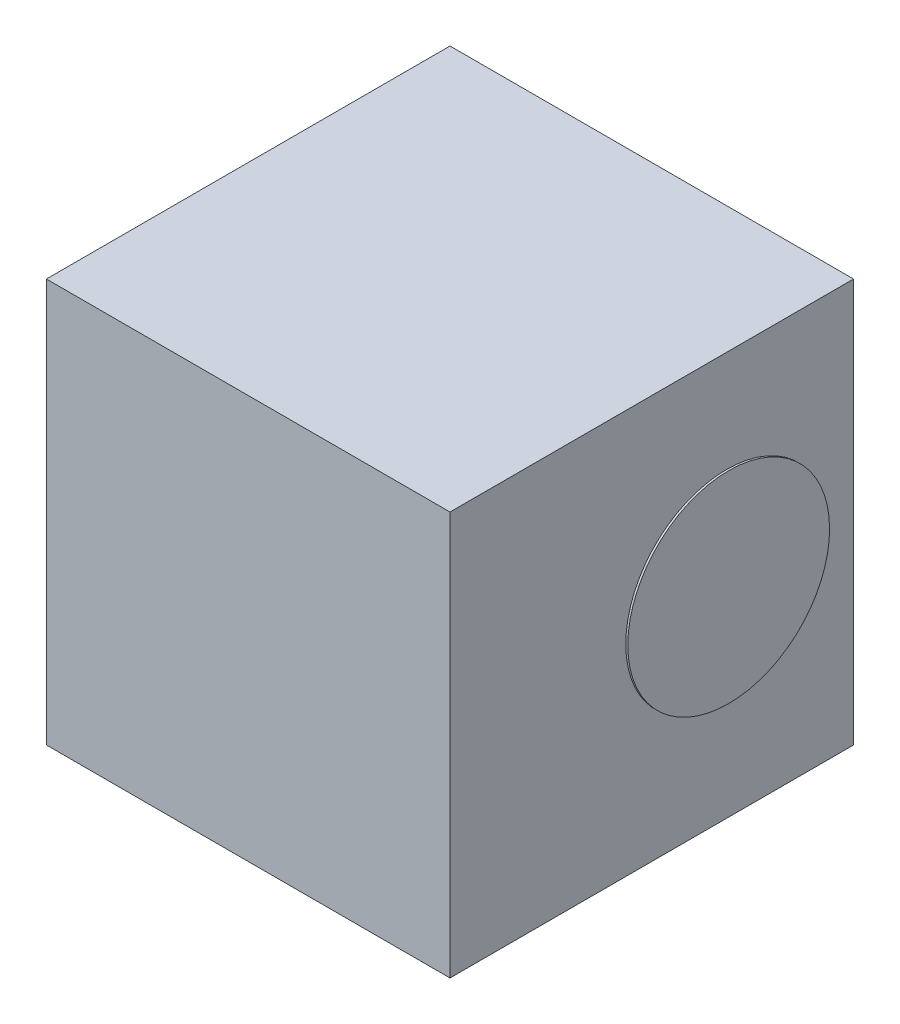
from build123d import *

# Parameters (mm, degrees)
SKETCH1_W           = 2
SKETCH1_H           = 2
BOSS_EXTRUDE1_DEPTH = 2
SKETCH2_R           = 0.5
BOSS_EXTRUDE2_DEPTH = 0.01


with BuildPart() as part:
    # Sketch1 → Boss-Extrude1 (new body)
    with BuildSketch(Plane(origin=(0, 0, 0), x_dir=(1, 0, 0), z_dir=(0, 1, 0))):
        Rectangle(SKETCH1_W, SKETCH1_H)
    extrude(amount=BOSS_EXTRUDE1_DEPTH)

    # Sketch2 → Boss-Extrude2 (add)
    with BuildSketch(Plane(origin=(1, 0, 0), x_dir=(0, 0, -1), z_dir=(1, 0, 0))):
        with Locations(Location((0.371123836, 0.997145201, 0), (0, 0, 180))):  # turned: the seam where the file's is
            Circle(SKETCH2_R)
    extrude(amount=BOSS_EXTRUDE2_DEPTH)


solid = part.part
